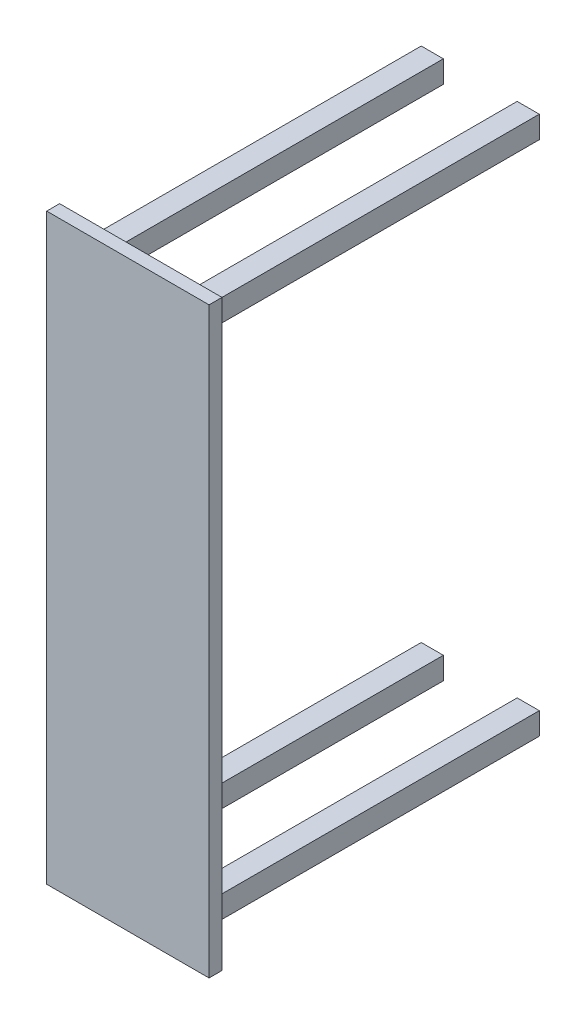
from build123d import *

# Parameters (mm, degrees)
SKETCH1_W           = 558.8
SKETCH1_H           = 2006.6
BOSS_EXTRUDE1_DEPTH = 44.45
SKETCH5_W           = 76.2
SKETCH5_H           = 76.2
BOSS_EXTRUDE2_DEPTH = 1168.4


with BuildPart() as part:
    # Sketch1 → Boss-Extrude1 (new body)
    with BuildSketch(Plane.XY):
        Rectangle(SKETCH1_W, SKETCH1_H)
    extrude(amount=BOSS_EXTRUDE1_DEPTH)

    # Sketch5 → Boss-Extrude2 (add)
    with BuildSketch(Plane(origin=(0, 0, 0), x_dir=(-1, 0, 0), z_dir=(0, 0, -1))):
        with Locations((-165.1, 889)):
            Rectangle(SKETCH5_W, SKETCH5_H)
        with Locations((165.1, 889)):
            Rectangle(SKETCH5_W, SKETCH5_H)
        with Locations((-165.1, -889)):
            Rectangle(SKETCH5_W, SKETCH5_H)
        with Locations((165.1, -889)):
            Rectangle(SKETCH5_W, SKETCH5_H)
    extrude(amount=BOSS_EXTRUDE2_DEPTH)


solid = part.part
